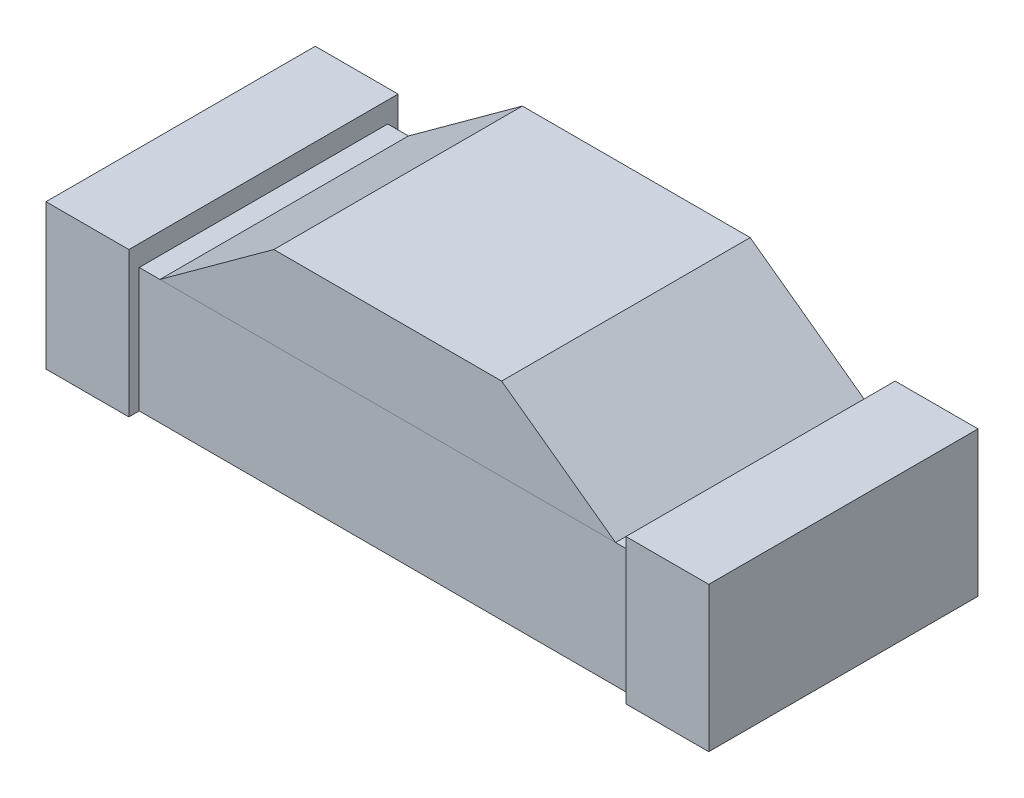
from build123d import *

# Parameters (mm, degrees)
BOSS_EXTRUDE1_DEPTH = 0.3
SKETCH3_W           = 0.2
SKETCH3_H           = 0.1
SKETCH4_W           = 0.2
SKETCH4_H           = 0.65
BOSS_EXTRUDE4_DEPTH = 0.35
BOSS_EXTRUDE5_DEPTH = 0.3


with BuildPart() as part:
    # Sketch1 → Boss-Extrude1 (new body)
    with BuildSketch(Plane(origin=(0, 0, 0), x_dir=(1, 0, 0), z_dir=(0, 1, 0))):
        with BuildLine():
            Line((-0.75, 0.3), (0.75, 0.3))
            Line((0.75, 0.3), (0.75, 0.125))
            ThreePointArc((0.75, 0.125), (0.625, 0), (0.75, -0.125))
            Line((0.75, -0.125), (0.75, -0.3))
            Line((0.75, -0.3), (-0.75, -0.3))
            Line((-0.75, -0.3), (-0.75, -0.125))
            ThreePointArc((-0.75, -0.125), (-0.625, 0), (-0.75, 0.125))
            Line((-0.75, 0.125), (-0.75, 0.3))
        make_face()
    extrude(amount=BOSS_EXTRUDE1_DEPTH)

    # Sketch3 → Revolve1 (revolve)
    with BuildSketch(Plane.XY):
        with Locations((0.1, 0.35)):
            Rectangle(SKETCH3_W, SKETCH3_H)
    revolve(axis=Axis((0, 0.809216282, 0), (0, -1, 0)))

    # Sketch4 → Boss-Extrude4 (add)
    with BuildSketch(Plane(origin=(0, 0, 0), x_dir=(1, 0, 0), z_dir=(0, 1, 0))):
        with Locations((-0.7, 0)):
            Rectangle(SKETCH4_W, SKETCH4_H)
    boss_extrude4 = extrude(amount=BOSS_EXTRUDE4_DEPTH)

    # Symétrie1: Boss-Extrude4 across plane
    add(boss_extrude4.mirror(Plane(origin=(0, 0, 0), x_dir=(0, 0, 1), z_dir=(1, 0, 0))))


with BuildPart() as body_2:
    # Sketch2 → Boss-Extrude5 (new body, symmetric)
    with BuildSketch(Plane.XY):
        Polygon((-0.55, 0.3), (0.55, 0.3), (0.275, 0.5), (-0.275, 0.5), align=None)
    extrude(amount=BOSS_EXTRUDE5_DEPTH, both=True)


solid = Compound([part.part, body_2.part])
